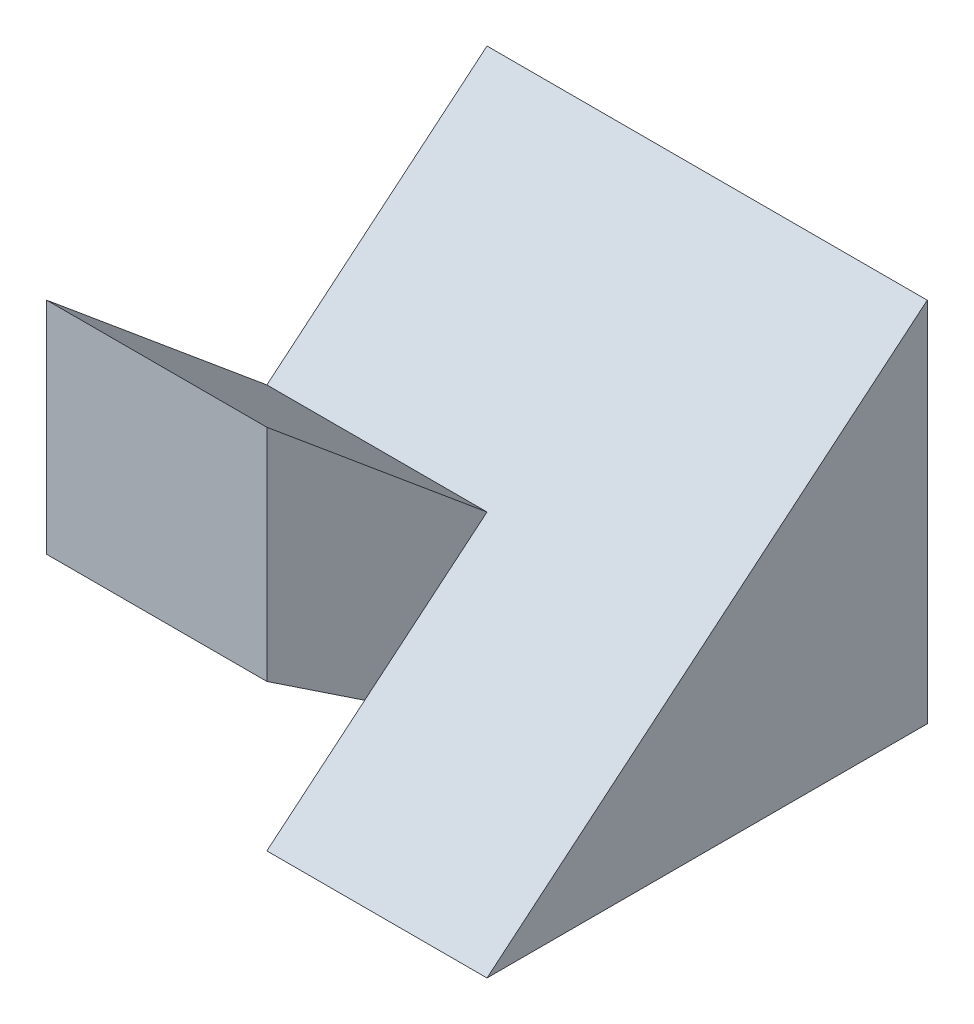
from build123d import *

# Parameters (mm, degrees)
SKETCH1_W           = 6
SKETCH1_H           = 6
BOSS_EXTRUDE1_DEPTH = 5
CUT_EXTRUDE1_DEPTH  = 10
CUT_EXTRUDE2_DEPTH  = 3
CUT_EXTRUDE3_DEPTH  = 3


with BuildPart() as part:
    # Sketch1 → Boss-Extrude1 (new body)
    with BuildSketch(Plane(origin=(0, 0, 0), x_dir=(1, 0, 0), z_dir=(0, 1, 0))):
        Rectangle(SKETCH1_W, SKETCH1_H)
    extrude(amount=BOSS_EXTRUDE1_DEPTH)

    # Sketch2 → Cut-Extrude1 (cut)
    with BuildSketch(Plane.ZY.offset(3)):
        Polygon((3, 5), (-3, 5), (0, 2.5), align=None)
    extrude(amount=-CUT_EXTRUDE1_DEPTH, mode=Mode.SUBTRACT)

    # Sketch3 → Cut-Extrude2 (cut)
    with BuildSketch(Plane(origin=(3, 0, 0), x_dir=(0, 0, -1), z_dir=(1, 0, 0))):
        Polygon((-3, 0), (0, 2.5), (-3, 5), align=None)
    extrude(amount=-CUT_EXTRUDE2_DEPTH, mode=Mode.SUBTRACT)

    # Sketch4 → Cut-Extrude3 (cut)
    with BuildSketch(Plane.ZY.offset(3)):
        Polygon((0, 0), (3, 0), (3, 2), align=None)
    extrude(amount=-CUT_EXTRUDE3_DEPTH, mode=Mode.SUBTRACT)


solid = part.part
